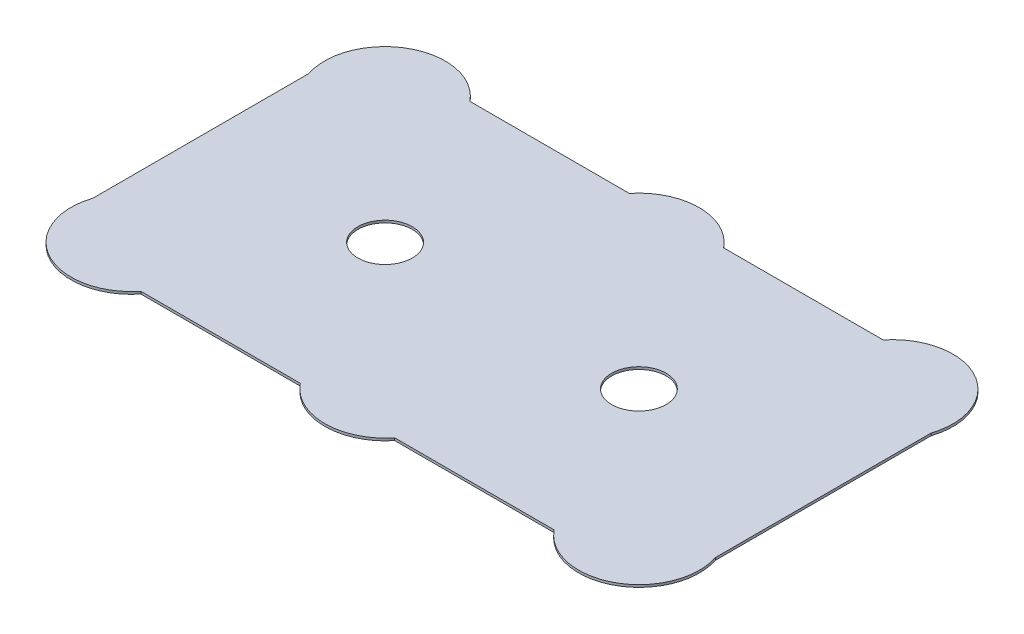
from build123d import *

# Parameters (mm, degrees)
SKETCH1_R           = 2.25
BOSS_EXTRUDE1_DEPTH = 0.2


with BuildPart() as part:
    # Sketch1 → Boss-Extrude1 (new body)
    with BuildSketch(Plane(origin=(0, 0, 0), x_dir=(1, 0, 0), z_dir=(0, 1, 0))):
        with BuildLine():
            Line((0.25, 24.4087505), (0.25, 6.5612495))
            ThreePointArc((0.25, 6.5612495), (2.618921791, 0.603357354), (8.903123749, 1.875))
            Line((8.903123749, 1.875), (22.096876251, 1.875))
            ThreePointArc((22.096876251, 1.875), (26, 0), (29.903123749, 1.875))
            Line((29.903123749, 1.875), (43.096876251, 1.875))
            ThreePointArc((43.096876251, 1.875), (49.381078209, 0.603357354), (51.75, 6.5612495))
            Line((51.75, 6.5612495), (51.75, 24.4087505))
            ThreePointArc((51.75, 24.4087505), (49.381078209, 30.366642646), (43.096876251, 29.095))
            Line((43.096876251, 29.095), (29.903123749, 29.095))
            ThreePointArc((29.903123749, 29.095), (26, 30.97), (22.096876251, 29.095))
            Line((22.096876251, 29.095), (8.903123749, 29.095))
            ThreePointArc((8.903123749, 29.095), (2.618921791, 30.366642646), (0.25, 24.4087505))
        make_face()
        with Locations((15.5, 15.485)):
            Circle(SKETCH1_R, mode=Mode.SUBTRACT)
        with Locations((36.5, 15.485)):
            Circle(SKETCH1_R, mode=Mode.SUBTRACT)
    extrude(amount=BOSS_EXTRUDE1_DEPTH)


solid = part.part
